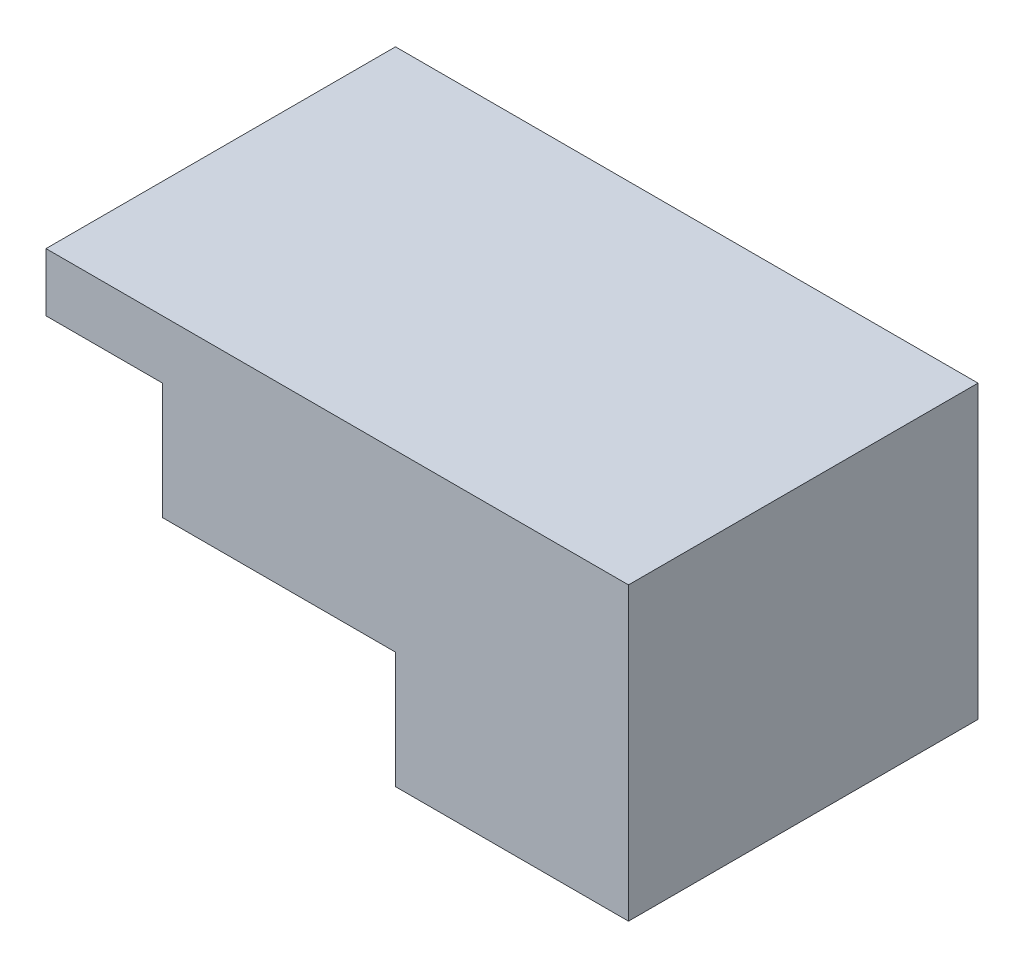
from build123d import *

# Parameters (mm, degrees)
BOSS_EXTRUDE3_DEPTH = 152.4


with BuildPart() as part:
    # Sketch1 → Boss-Extrude3 (new body)
    with BuildSketch(Plane.XY):
        Polygon((0, 0), (0, -50.8), (101.6, -50.8), (101.6, 76.2), (-152.4, 76.2), (-152.4, 50.8), (-101.6, 50.8), (-101.6, 0), align=None)
    extrude(amount=-BOSS_EXTRUDE3_DEPTH)


solid = part.part
